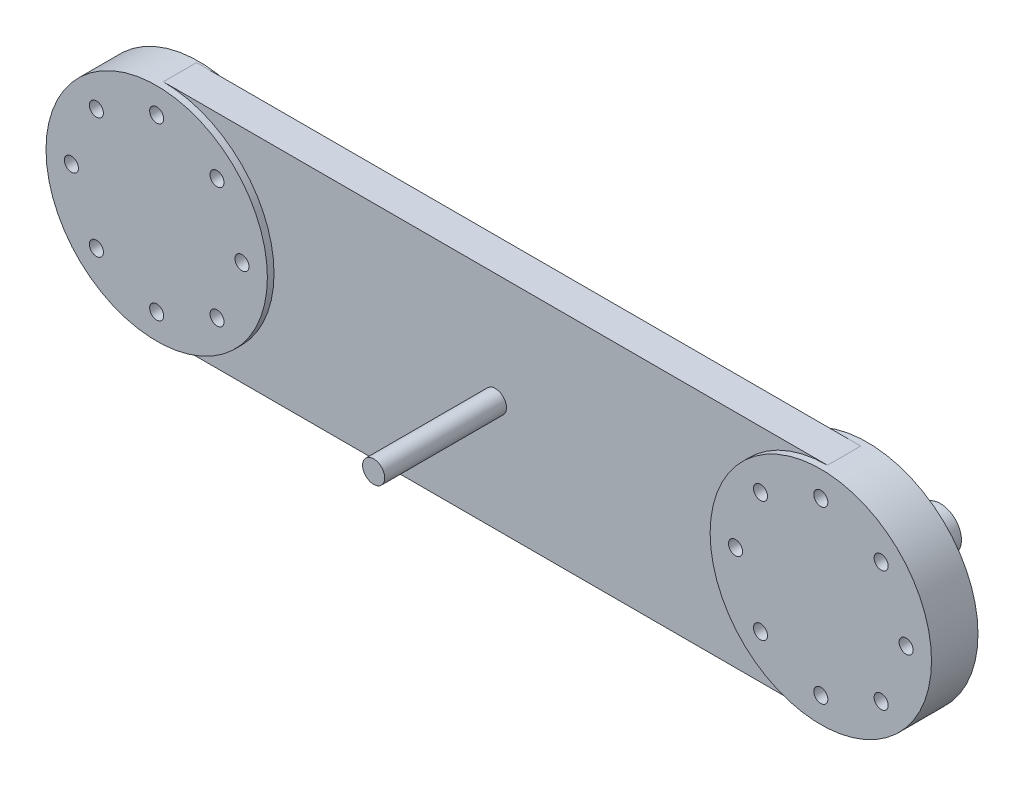
from build123d import *

# Parameters (mm, degrees)
SKETCH_1_R                         = 50
EXTRUDE_18_DEPTH                   = 13
EXTRUDE_18_2_DEPTH                 = 13
SKETCH_1_28_W                      = 300
SKETCH_1_28_H                      = 100
EXTRUDE_21_DEPTH                   = 15
SKETCH_1_30_R                      = 5
EXTRUDE_22_DEPTH                   = 70
SKETCH_1_31_R                      = 50
CUT_EXTRUDE_2_DEPTH                = 41
SKETCH_1_32_R                      = 50
EXTRUDE_23_DEPTH                   = 18
EXTRUDE_23_DEPTH_BACK              = 1
SKETCH_1_35_R                      = 3.175
CUT_EXTRUDE_5_DEPTH                = 130
CUT_EXTRUDE_5_DEPTH_BACK           = 69
SKETCH_1_36_R                      = 50
CUT_EXTRUDE_6_DEPTH                = 34
SKETCH_1_37_R                      = 50
EXTRUDE_24_DEPTH                   = 18
EXTRUDE_24_DEPTH_BACK              = 3
SKETCH_1_41_R                      = 3.175
CUT_EXTRUDE_7_DEPTH                = 87
CUT_EXTRUDE_7_DEPTH_BACK           = 98
THE_EXTENDED_SHAFT_CONNECTER_DEPTH = 36
SKETCH_3_R                         = 1.0922
CUT_EXTRUDE_8_DEPTH                = 31
SKETCH_5_R                         = 1.0922
SCREW_HOLES2_DEPTH                 = 47.995932


with BuildPart() as part:
    # 草图1 → 凸台-拉伸18 (new body)
    with BuildSketch(Plane.XY):
        with Locations((0, 50)):
            Circle(SKETCH_1_R)
    extrude(amount=EXTRUDE_18_DEPTH)



with BuildPart() as body_2:
    # 草图1 → Extrude 18 2 (new body)
    with BuildSketch(Plane.XY):
        with Locations((-300, 50)):
            Circle(SKETCH_1_R)
    extrude(amount=EXTRUDE_18_2_DEPTH)


with BuildPart() as part_1:
    add(part.part)

    add(body_2.part)  # 凸台-拉伸21 merges body 2
    # 草图1<28> → 凸台-拉伸21 (add)
    with BuildSketch(Plane.XY):
        with Locations((-150, 50)):
            Rectangle(SKETCH_1_28_W, SKETCH_1_28_H)
    extrude(amount=EXTRUDE_21_DEPTH)

    # 草图1<30> → 凸台-拉伸22 (add)
    with BuildSketch(Plane.XY):
        with Locations((-150, 50)):
            Circle(SKETCH_1_30_R)
    extrude(amount=EXTRUDE_22_DEPTH)

    # 草图1<31> → 切除-拉伸2 (cut)
    with BuildSketch(Plane.XY):
        with Locations((-300, 50)):
            Circle(SKETCH_1_31_R)
    extrude(amount=CUT_EXTRUDE_2_DEPTH, mode=Mode.SUBTRACT)

    # 草图1<32> → 凸台-拉伸23 (add, two sides)
    with BuildSketch(Plane.XY) as extrude_23_sk:
        with Locations((-300, 50)):
            Circle(SKETCH_1_32_R)
    extrude(amount=EXTRUDE_23_DEPTH)
    extrude(extrude_23_sk.sketch, amount=-EXTRUDE_23_DEPTH_BACK)

    # 草图1<35> → 切除-拉伸5 (cut, two sides)
    with BuildSketch(Plane.XY) as cut_extrude_5_sk:
        with Locations((-261.469660941, 50)):
            Circle(SKETCH_1_35_R)
    extrude(amount=CUT_EXTRUDE_5_DEPTH, mode=Mode.SUBTRACT)
    extrude(cut_extrude_5_sk.sketch, amount=-CUT_EXTRUDE_5_DEPTH_BACK, mode=Mode.SUBTRACT)

    # 草图1<36> → 切除-拉伸6 (cut)
    with BuildSketch(Plane.XY):
        with Locations((0, 50)):
            Circle(SKETCH_1_36_R)
    extrude(amount=CUT_EXTRUDE_6_DEPTH, mode=Mode.SUBTRACT)

    # 草图1<37> → 凸台-拉伸24 (add, two sides)
    with BuildSketch(Plane.XY) as extrude_24_sk:
        with Locations((0, 50)):
            Circle(SKETCH_1_37_R)
    extrude(amount=EXTRUDE_24_DEPTH)
    extrude(extrude_24_sk.sketch, amount=-EXTRUDE_24_DEPTH_BACK)

    # 草图1<41> → 切除-拉伸7 (cut, two sides)
    with BuildSketch(Plane.XY) as cut_extrude_7_sk:
        with Locations((-272.75493597, 77.24506403)):
            Circle(SKETCH_1_41_R)
        with BuildLine():
            ThreePointArc((-296.825, 88.530339059), (-297.75493597, 90.77540309), (-300, 91.705339059))
            Line((-300, 91.705339059), (-300, 85.355339059))
            ThreePointArc((-300, 85.355339059), (-297.75493597, 86.285275029), (-296.825, 88.530339059))
        make_face()
        with BuildLine():
            Line((-300, 85.355339059), (-300, 91.705339059))
            ThreePointArc((-300, 91.705339059), (-303.175, 88.530339059), (-300, 85.355339059))
        make_face()
        with Locations((-327.24506403, 77.24506403)):
            Circle(SKETCH_1_41_R)
        with Locations((-338.530339059, 50)):
            Circle(SKETCH_1_41_R)
        with BuildLine():
            ThreePointArc((-325, 25), (-329.490128061, 25), (-329.490128061, 20.509871939))
            Line((-329.490128061, 20.509871939), (-325, 25))
        make_face()
        with BuildLine():
            Line((-325, 25), (-329.490128061, 20.509871939))
            ThreePointArc((-329.490128061, 20.509871939), (-326.030044133, 19.821618454), (-324.07006403, 22.75493597))
            ThreePointArc((-324.07006403, 22.75493597), (-324.311746515, 23.969955867), (-325, 25))
        make_face()
        with BuildLine():
            ThreePointArc((-300, 14.644660941), (-303.175, 11.469660941), (-300, 8.294660941))
            Line((-300, 8.294660941), (-300, 14.644660941))
        make_face()
        with BuildLine():
            Line((-300, 14.644660941), (-300, 8.294660941))
            ThreePointArc((-300, 8.294660941), (-297.75493597, 9.22459691), (-296.825, 11.469660941))
            ThreePointArc((-296.825, 11.469660941), (-297.75493597, 13.714724971), (-300, 14.644660941))
        make_face()
        with Locations((-272.75493597, 22.75493597)):
            Circle(SKETCH_1_41_R)
        with BuildLine():
            ThreePointArc((-264.644660941, 50), (-261.469660941, 46.825), (-258.294660941, 50))
            Line((-258.294660941, 50), (-264.644660941, 50))
        make_face()
        with BuildLine():
            Line((-264.644660941, 50), (-258.294660941, 50))
            ThreePointArc((-258.294660941, 50), (-261.469660941, 53.175), (-264.644660941, 50))
        make_face()
        with Locations((-27.24506403, 22.75493597)):
            Circle(SKETCH_1_41_R)
        with Locations((-38.530339059, 50)):
            Circle(SKETCH_1_41_R)
        with Locations((-27.24506403, 77.24506403)):
            Circle(SKETCH_1_41_R)
        with BuildLine():
            ThreePointArc((3.175, 88.530339059), (2.24506403, 90.77540309), (0, 91.705339059))
            Line((0, 91.705339059), (0, 85.355339059))
            ThreePointArc((0, 85.355339059), (2.24506403, 86.285275029), (3.175, 88.530339059))
        make_face()
        with BuildLine():
            Line((0, 85.355339059), (0, 91.705339059))
            ThreePointArc((0, 91.705339059), (-3.175, 88.530339059), (0, 85.355339059))
        make_face()
        with Locations((27.24506403, 77.24506403)):
            Circle(SKETCH_1_41_R)
        with Locations((27.24506403, 22.75493597)):
            Circle(SKETCH_1_41_R)
        with Locations((38.530339059, 50)):
            Circle(SKETCH_1_41_R)
        with BuildLine():
            ThreePointArc((0, 14.644660941), (-3.175, 11.469660941), (0, 8.294660941))
            Line((0, 8.294660941), (0, 14.644660941))
        make_face()
        with BuildLine():
            Line((0, 14.644660941), (0, 8.294660941))
            ThreePointArc((0, 8.294660941), (2.24506403, 9.22459691), (3.175, 11.469660941))
            ThreePointArc((3.175, 11.469660941), (2.24506403, 13.714724971), (0, 14.644660941))
        make_face()
    extrude(amount=CUT_EXTRUDE_7_DEPTH, mode=Mode.SUBTRACT)
    extrude(cut_extrude_7_sk.sketch, amount=-CUT_EXTRUDE_7_DEPTH_BACK, mode=Mode.SUBTRACT)

    # 草图1<43> → the extended shaft connecter (add)
    with BuildSketch(Plane.XY):
        with BuildLine():
            Line((0, 43.75), (0, 40.475))
            ThreePointArc((0, 40.475), (6.735192091, 43.264807909), (9.525, 50))
            ThreePointArc((9.525, 50), (6.735192091, 56.735192091), (0, 59.525))
            Line((0, 59.525), (0, 56.25))
            ThreePointArc((0, 56.25), (3.642600233, 55.078775791), (5.919983963, 52.004068333))
            Line((5.919983963, 52.004068333), (6.25, 52.004068333))
            Line((6.25, 52.004068333), (8.25, 52.004068333))
            Line((8.25, 52.004068333), (8.25, 50))
            Line((8.25, 50), (8.25, 47.995931667))
            Line((8.25, 47.995931667), (6.25, 47.995931667))
            Line((6.25, 47.995931667), (5.919983963, 47.995931667))
            ThreePointArc((5.919983963, 47.995931667), (3.642600233, 44.921224209), (0, 43.75))
        make_face()
        with BuildLine():
            ThreePointArc((0, 59.525), (-9.525, 50), (0, 40.475))
            Line((0, 40.475), (0, 43.75))
            ThreePointArc((0, 43.75), (-6.25, 50), (0, 56.25))
            Line((0, 56.25), (0, 59.525))
        make_face()
    extrude(amount=-THE_EXTENDED_SHAFT_CONNECTER_DEPTH)

    # 草图3 → 切除-拉伸8 (cut)
    with BuildSketch(Plane(origin=(0, 0, 0), x_dir=(0, 0, -1), z_dir=(1, 0, 0))):
        with Locations((32, 50)):
            Circle(SKETCH_3_R)
        with Locations((27, 50)):
            Circle(SKETCH_3_R)
    extrude(amount=-CUT_EXTRUDE_8_DEPTH, mode=Mode.SUBTRACT)

    # 草图5 → screw_holes2 (cut)
    with BuildSketch(Plane(origin=(0, 0, 0), x_dir=(1, 0, 0), z_dir=(0, 1, 0))):
        with Locations((0, 32)):
            Circle(SKETCH_5_R)
        with Locations((0, 27)):
            Circle(SKETCH_5_R)
    extrude(amount=SCREW_HOLES2_DEPTH, mode=Mode.SUBTRACT)


solid = part_1.part
